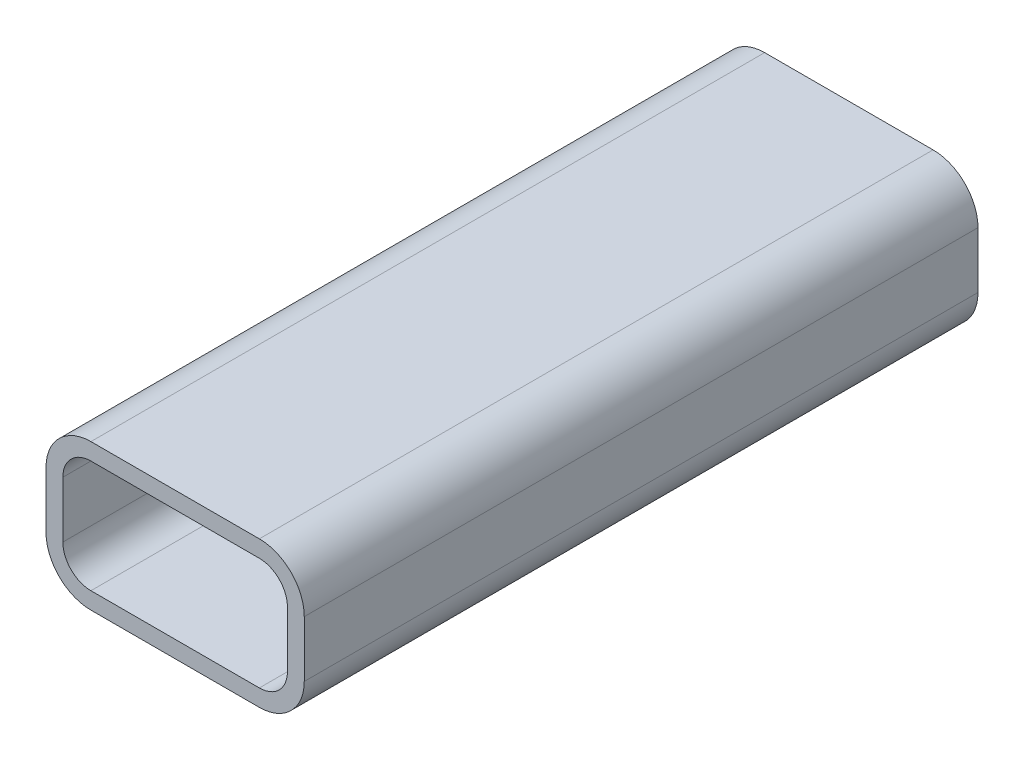
from build123d import *

# Parameters (mm, degrees)
EXTRUDE_THIN1_DEPTH = 60


with BuildPart() as part:
    # Sketch1 → Extrude-Thin1 (new body, symmetric)
    with BuildSketch(Plane.XY):
        with BuildLine():
            Line((32.051705101, -4.051705101), (32.051705101, -14.051705101))
            ThreePointArc((32.051705101, -14.051705101), (29.70855935, -19.70855935), (24.051705101, -22.051705101))
            Line((24.051705101, -22.051705101), (-5.948294899, -22.051705101))
            ThreePointArc((-5.948294899, -22.051705101), (-11.605149149, -19.70855935), (-13.948294899, -14.051705101))
            Line((-13.948294899, -14.051705101), (-13.948294899, -4.051705101))
            ThreePointArc((-13.948294899, -4.051705101), (-11.605149149, 1.605149149), (-5.948294899, 3.948294899))
            Line((-5.948294899, 3.948294899), (24.051705101, 3.948294899))
            ThreePointArc((24.051705101, 3.948294899), (29.70855935, 1.605149149), (32.051705101, -4.051705101))
        make_face()
        with BuildLine():
            Line((29.051705101, -4.051705101), (29.051705101, -14.051705101))
            ThreePointArc((29.051705101, -14.051705101), (27.587239007, -17.587239007), (24.051705101, -19.051705101))
            Line((24.051705101, -19.051705101), (-5.948294899, -19.051705101))
            ThreePointArc((-5.948294899, -19.051705101), (-9.483828805, -17.587239007), (-10.948294899, -14.051705101))
            Line((-10.948294899, -14.051705101), (-10.948294899, -4.051705101))
            ThreePointArc((-10.948294899, -4.051705101), (-9.483828805, -0.516171195), (-5.948294899, 0.948294899))
            Line((-5.948294899, 0.948294899), (24.051705101, 0.948294899))
            ThreePointArc((24.051705101, 0.948294899), (27.587239007, -0.516171195), (29.051705101, -4.051705101))
        make_face(mode=Mode.SUBTRACT)
    extrude(amount=EXTRUDE_THIN1_DEPTH, both=True)


solid = part.part
